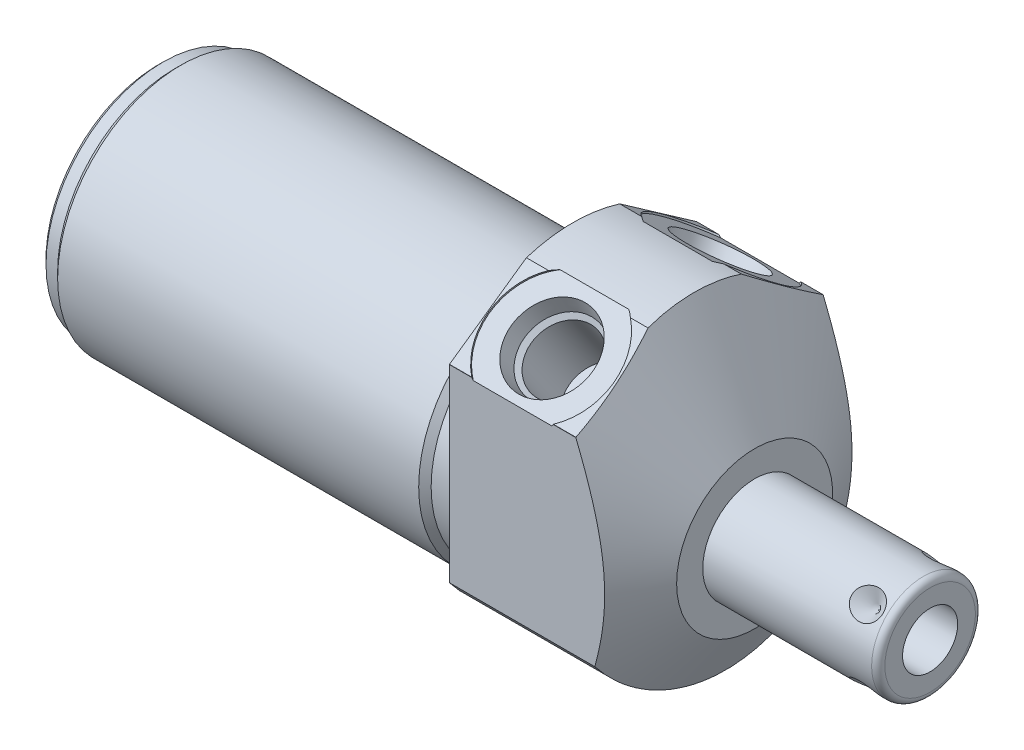
from build123d import *

# Parameters (mm, degrees)
SKETCH1_R           = 23.8125
EXTRUDE1_DEPTH      = 27.7876
EXTRUDE1_DEPTH_BACK = 63.5
CUT_EXTRUDE1_REACH  = 65.5
SKETCH2_R           = 23.8125
SKETCH2_R_2         = 18.8595
CUT_EXTRUDE3_START  = -27.7876
SKETCH4_R           = 28.575
CUT_EXTRUDE3_DEPTH  = 27.7876
SKETCH18_R          = 9.525
CUT_EXTRUDE4_DEPTH  = 0.254
SKETCH19_R          = 9.525
CUT_EXTRUDE5_DEPTH  = 0.254
CHAMFER1_SIZE       = 0.762
CIRPATTERN1_COUNT   = 4


with BuildPart() as part:
    # Sketch1 → Extrude1 (new body, two sides)
    with BuildSketch(Plane(origin=(0, 0, 0), x_dir=(0, 0, -1), z_dir=(1, 0, 0))) as extrude1_sk:
        Circle(SKETCH1_R)
    extrude(amount=EXTRUDE1_DEPTH)
    extrude(extrude1_sk.sketch, amount=-EXTRUDE1_DEPTH_BACK)

    # Sketch2 → Cut-Extrude1 (cut, up to next)
    with BuildSketch(Plane(origin=(0, 0, 0), x_dir=(0, 0, -1), z_dir=(1, 0, 0)), mode=Mode.PRIVATE) as cut_extrude1_sk1:
        Circle(SKETCH2_R)
        with Locations((0, -4.191)):
            Circle(SKETCH2_R_2, mode=Mode.SUBTRACT)
    cut_extrude1_tool1 = extrude(cut_extrude1_sk1.sketch, amount=-CUT_EXTRUDE1_REACH, mode=Mode.PRIVATE) & part.part
    add(cut_extrude1_tool1.solids().sort_by_distance((0, 0, 23.138981))[0], mode=Mode.SUBTRACT)

    # Sketch4 → Cut-Extrude3 (cut)
    with BuildSketch(Plane.ZY.offset(CUT_EXTRUDE3_START)):
        Circle(SKETCH4_R)
        with BuildLine():
            Line((18.923, -14.455283714), (18.923, 14.465869871))
            Line((18.923, 14.465869871), (0, 27.715897117))
            Line((0, 27.715897117), (-18.923, 14.465869871))
            Line((-18.923, 14.465869871), (-18.923, -14.455283714))
            ThreePointArc((-18.923, -14.455283714), (0, -23.8125), (18.923, -14.455283714))
        make_face(mode=Mode.SUBTRACT)
    extrude(amount=CUT_EXTRUDE3_DEPTH, mode=Mode.SUBTRACT)

    # Sketch6 → Cut-Revolve2 (revolve, cut)
    with BuildSketch(Plane.XY, mode=Mode.PRIVATE) as cut_revolve2_sk:
        Polygon((4.764025965, 47.625), (27.7876, 7.747), (27.7876, 47.625), align=None)
    revolve(cut_revolve2_sk.sketch.rotate(Axis((3.612847264, -4.191, 0), (1, 0, 0)), 270), axis=Axis((3.612847264, -4.191, 0), (1, 0, 0)), mode=Mode.SUBTRACT)  # turned: the seam where the file's is

    # S2D0002 → Cut-Revolve3 (revolve, cut)
    with BuildSketch(Plane(origin=(9.652, 18.394824642, 12.869035589), x_dir=(0, 0.573576436, -0.819152044), z_dir=(1, 0, 0))):
        Polygon((0, 0), (6.1849, 0), (5.642306865, -2.5527), (4.9784, -3.216606865), (4.9784, -13.462), (0, -13.462), align=None)
    revolve(axis=Axis((9.652, 6.816028581, 4.761475303), (0, 0.819152044, 0.573576436)), mode=Mode.SUBTRACT)

    # Sketch8 → Cut-Revolve4 (revolve, cut)
    with BuildSketch(Plane(origin=(9.652, 18.394824642, -12.869035589), x_dir=(0, -0.573576436, -0.819152044), z_dir=(1, 0, 0))):
        Polygon((0, 0), (6.1849, 0), (5.642306865, -2.5527), (4.9784, -3.216606865), (4.9784, -13.462), (0, -13.462), align=None)
    revolve(axis=Axis((9.652, 6.816028581, -4.761475303), (0, 0.819152044, -0.573576436)), mode=Mode.SUBTRACT)

    # Sketch18 → Cut-Extrude4 (cut)
    with BuildSketch(Plane(origin=(0, 18.59764611, 13.022211999), x_dir=(1, 0, 0), z_dir=(0, 0.819152044, 0.573576436))):
        with Locations((9.652, 0.009141155)):
            Circle(SKETCH18_R)
    extrude(amount=-CUT_EXTRUDE4_DEPTH, mode=Mode.SUBTRACT)

    # Sketch19 → Cut-Extrude5 (cut)
    with BuildSketch(Plane(origin=(0, 18.59764611, -13.022211999), x_dir=(1, 0, 0), z_dir=(0, 0.819152044, -0.573576436))):
        with Locations((9.652, -0.009141155)):
            Circle(SKETCH19_R)
    extrude(amount=-CUT_EXTRUDE5_DEPTH, mode=Mode.SUBTRACT)

    # Sketch10 → Cut-Revolve6 (revolve, cut)
    with BuildSketch(Plane.XY, mode=Mode.PRIVATE) as cut_revolve6_sk:
        Polygon((0, 14.6685), (0, 13.716), (-3.81, 13.716), (-4.7625, 14.6685), align=None)
    revolve(cut_revolve6_sk.sketch.rotate(Axis((-5.000625, -4.191, 0), (1, 0, 0)), 90), axis=Axis((-5.000625, -4.191, 0), (1, 0, 0)), mode=Mode.SUBTRACT)  # turned: the seam where the file's is

    # Sketch12 → Cut-Revolve8 (revolve, cut)
    with BuildSketch(Plane.XY, mode=Mode.PRIVATE) as cut_revolve8_sk:
        Polygon((-63.5, 14.6685), (-63.5, 13.716), (-60.96, 13.716), (-60.0075, 14.6685), align=None)
    revolve(cut_revolve8_sk.sketch.rotate(Axis((-63.674625, -4.191, 0), (1, 0, 0)), 90), axis=Axis((-63.674625, -4.191, 0), (1, 0, 0)), mode=Mode.SUBTRACT)  # turned: the seam where the file's is

    # Chamfer1
    chamfer1_edges = [part.edges().sort_by_distance(p)[0] for p in [
        (-63.5, -4.191, -17.907),
    ]]
    chamfer(chamfer1_edges, length=CHAMFER1_SIZE)

    # Sketch13 → Revolve1 (revolve)
    with BuildSketch(Plane(origin=(0, 0, 0), x_dir=(0, -1, 0), z_dir=(0, 0, 1)), mode=Mode.PRIVATE) as revolve1_sk:
        with BuildLine():
            Line((4.191, 27.7876), (4.191, 54.6354))
            Line((4.191, 54.6354), (11.1125, 54.6354))
            ThreePointArc((11.1125, 54.6354), (11.83092049, 54.33782049), (12.1285, 53.6194))
            Line((12.1285, 53.6194), (12.1285, 27.7876))
            Line((12.1285, 27.7876), (4.191, 27.7876))
        make_face()
    revolve(revolve1_sk.sketch.rotate(Axis((26.44521, -4.191, 0), (1, 0, 0)), 270), axis=Axis((26.44521, -4.191, 0), (1, 0, 0)))  # turned: the seam where the file's is

    # S2D0001 → Cut-Revolve9 (revolve, cut)
    with BuildSketch(Plane(origin=(54.6354, -8.4074, 0), x_dir=(0, -1, 0), z_dir=(0, 0, 1)), mode=Mode.PRIVATE) as cut_revolve9_sk:
        Polygon((0, 0), (0, -15.24), (-4.2164, -17.773468714), (-4.2164, 0), align=None)
    revolve(cut_revolve9_sk.sketch.rotate(Axis((35.97325785, -4.191, 0), (1, 0, 0)), 270), axis=Axis((35.97325785, -4.191, 0), (1, 0, 0)), mode=Mode.SUBTRACT)  # turned: the seam where the file's is

    # Sketch16 → Cut-Revolve10 (revolve, cut)
    with BuildSketch(Plane(origin=(50.673, 1.421660076, -5.612660076), x_dir=(-1, 0, 0), z_dir=(0, -0.707106781, -0.707106781)), mode=Mode.PRIVATE) as cut_revolve10_sk:
        Polygon((0, 0), (2.413, 0), (0, -2.413), align=None)
    cut_revolve10 = revolve(cut_revolve10_sk.sketch.rotate(Axis((50.673, -2.1640922, -2.0269078), (0, 0.707106781, -0.707106781)), 90), axis=Axis((50.673, -2.1640922, -2.0269078), (0, 0.707106781, -0.707106781)), mode=Mode.SUBTRACT)  # turned: the seam where the file's is

    # CirPattern1: Cut-Revolve10 ×4 about axis
    cirpattern1_axis = Axis((26.44521, -4.191, 0), (-1, 0, 0))
    for i in range(1, CIRPATTERN1_COUNT):
        add(cut_revolve10.rotate(cirpattern1_axis, i * 360 / CIRPATTERN1_COUNT), mode=Mode.SUBTRACT)


solid = part.part
